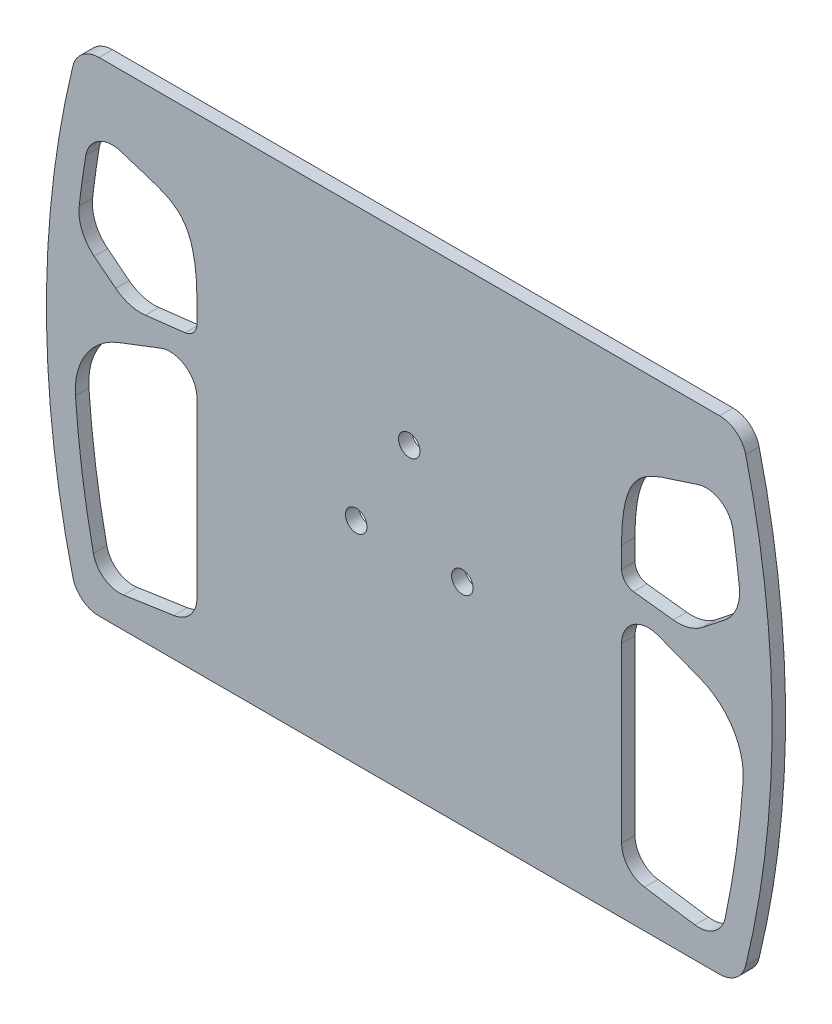
from build123d import *

# Parameters (mm, degrees)
BOSS_EXTRUDE1_DEPTH = 5
SKETCH2_R           = 4
CUT_EXTRUDE1_DEPTH  = 5
CUT_EXTRUDE4_DEPTH  = 35


with BuildPart() as part:
    # Sketch1 → Boss-Extrude1 (new body)
    with BuildSketch(Plane.XY):
        with BuildLine():
            Line((115.454232837, -90), (-115.454232837, -90))
            ThreePointArc((-115.454232837, -90), (-121.637702261, -87.85905248), (-125.173474979, -82.352941176))
            ThreePointArc((-125.173474979, -82.352941176), (-135, 0), (-125.173474979, 82.352941176))
            ThreePointArc((-125.173474979, 82.352941176), (-121.637702261, 87.85905248), (-115.454232837, 90))
            Line((-115.454232837, 90), (115.454232837, 90))
            ThreePointArc((115.454232837, 90), (121.637702261, 87.85905248), (125.173474979, 82.352941176))
            ThreePointArc((125.173474979, 82.352941176), (135, 0), (125.173474979, -82.352941176))
            ThreePointArc((125.173474979, -82.352941176), (121.637702261, -87.85905248), (115.454232837, -90))
        make_face()
    extrude(amount=BOSS_EXTRUDE1_DEPTH)

    # Sketch2 → Cut-Extrude1 (cut)
    with BuildSketch(Plane.XY.offset(5)):
        with Locations((0, 22.8)):
            Circle(SKETCH2_R)
        with Locations((19.745379206, -11.4)):
            Circle(SKETCH2_R)
        with Locations((-19.745379206, -11.4)):
            Circle(SKETCH2_R)
    extrude(amount=-CUT_EXTRUDE1_DEPTH, mode=Mode.SUBTRACT)

    # Sketch4 → Cut-Extrude4 (cut)
    with BuildSketch(Plane.XY.offset(5)):
        with BuildLine():
            Line((92.589613382, 7.756373084), (108.233016215, 1.740021021))
            ThreePointArc((108.233016215, 1.740021021), (120.339926562, -8.155270139), (124.200171868, -23.307582551))
            ThreePointArc((124.200171868, -23.307582551), (121.709079907, -47.191053261), (117.538445446, -70.839129726))
            ThreePointArc((117.538445446, -70.839129726), (113.463443203, -76.968226609), (106.297665816, -78.648436814))
            Line((106.297665816, -78.648436814), (87.539762883, -75.879659935))
            ThreePointArc((87.539762883, -75.879659935), (81.430245342, -72.521282016), (79, -65.986849032))
            Line((79, -65.986849032), (79, -1.577151211))
            ThreePointArc((79, -1.577151211), (83.338557331, 6.665910532), (92.589613382, 7.756373084))
        make_face()
        with BuildLine():
            ThreePointArc((-92.589613382, 7.756373084), (-83.338557331, 6.665910532), (-79, -1.577151211))
            Line((-79, -1.577151211), (-79, -65.986849032))
            ThreePointArc((-79, -65.986849032), (-81.430245342, -72.521282016), (-87.539762883, -75.879659935))
            Line((-87.539762883, -75.879659935), (-106.297665816, -78.648436814))
            ThreePointArc((-106.297665816, -78.648436814), (-113.463443203, -76.968226609), (-117.538445446, -70.839129726))
            ThreePointArc((-117.538445446, -70.839129726), (-121.709079907, -47.191053261), (-124.200171868, -23.307582551))
            ThreePointArc((-124.200171868, -23.307582551), (-120.339926562, -8.155270139), (-108.233016215, 1.740021021))
            Line((-108.233016215, 1.740021021), (-92.589613382, 7.756373084))
        make_face()
        with BuildLine():
            add(Edge.make_bspline(
                [(-107.1656403, 63.712244747), (-105.421734613, 63.094579339), (-103.733740594, 62.553921113), (-100.607161167, 61.582975733), (-99.159247663, 61.147865372), (-96.410321129, 60.288497128), (-95.109448347, 59.864130878), (-92.675824035, 58.977926734), (-91.543513421, 58.51617249), (-89.457956468, 57.516788843), (-88.505180062, 56.979898005), (-86.763629608, 55.791229907), (-85.974064887, 55.140456421), (-84.517341855, 53.654449203), (-83.848519279, 52.818369685), (-82.607884183, 50.851859219), (-82.036322501, 49.719874222), (-81.010476423, 47.056406193), (-80.557249512, 45.52494381), (-79.807126347, 41.990071718), (-79.510581534, 39.987228491), (-79.107044911, 35.456158677), (-79, 32.928236614), (-79, 30.112884289)],
                knots=[0.308064858, 0.308064858, 0.308064858, 0.308064858, 0.375, 0.375, 0.4375, 0.4375, 0.5, 0.5, 0.5625, 0.5625, 0.625, 0.625, 0.6875, 0.6875, 0.75, 0.75, 0.8125, 0.8125, 0.875, 0.875, 0.9375, 0.9375, 1, 1, 1, 1], degree=3))
            Line((-79, 30.112884289), (-79, 22.274807415))
            ThreePointArc((-79, 22.274807415), (-80.264551221, 18.95119155), (-83.418568967, 17.308728685))
            Line((-83.418568967, 17.308728685), (-98.190518564, 15.579221284))
            ThreePointArc((-98.190518564, 15.579221284), (-104.024603132, 16.045769918), (-109.236054023, 18.709412158))
            Line((-109.236054023, 18.709412158), (-117.213085535, 25.01430829))
            ThreePointArc((-117.213085535, 25.01430829), (-121.761034531, 31.020418271), (-122.815466707, 38.480000696))
            ThreePointArc((-122.815466707, 38.480000696), (-121.704826963, 47.22138816), (-120.368031746, 55.931058302))
            ThreePointArc((-120.368031746, 55.931058302), (-115.58177318, 62.901067623), (-107.1656403, 63.712244747))
        make_face()
        with BuildLine():
            add(Edge.make_bspline(
                [(107.1656403, 63.712244747), (105.421734613, 63.094579339), (103.733740594, 62.553921113), (100.607161167, 61.582975733), (99.159247663, 61.147865372), (96.410321129, 60.288497128), (95.109448347, 59.864130878), (92.675824035, 58.977926734), (91.543513421, 58.51617249), (89.457956468, 57.516788843), (88.505180062, 56.979898005), (86.763629608, 55.791229907), (85.974064887, 55.140456421), (84.517341855, 53.654449203), (83.848519279, 52.818369685), (82.607884183, 50.851859219), (82.036322501, 49.719874222), (81.010476423, 47.056406193), (80.557249512, 45.52494381), (79.807126347, 41.990071718), (79.510581534, 39.987228491), (79.107044911, 35.456158677), (79, 32.928236614), (79, 30.112884289)],
                knots=[0.308064858, 0.308064858, 0.308064858, 0.308064858, 0.375, 0.375, 0.4375, 0.4375, 0.5, 0.5, 0.5625, 0.5625, 0.625, 0.625, 0.6875, 0.6875, 0.75, 0.75, 0.8125, 0.8125, 0.875, 0.875, 0.9375, 0.9375, 1, 1, 1, 1], degree=3))
            Line((79, 30.112884289), (79, 22.274807415))
            ThreePointArc((79, 22.274807415), (80.264551221, 18.95119155), (83.418568967, 17.308728685))
            Line((83.418568967, 17.308728685), (98.190518564, 15.579221284))
            ThreePointArc((98.190518564, 15.579221284), (104.024603132, 16.045769918), (109.236054023, 18.709412158))
            Line((109.236054023, 18.709412158), (117.213085535, 25.01430829))
            ThreePointArc((117.213085535, 25.01430829), (121.761034531, 31.020418271), (122.815466707, 38.480000696))
            ThreePointArc((122.815466707, 38.480000696), (121.704826963, 47.22138816), (120.368031746, 55.931058302))
            ThreePointArc((120.368031746, 55.931058302), (115.58177318, 62.901067623), (107.1656403, 63.712244747))
        make_face()
    extrude(amount=-CUT_EXTRUDE4_DEPTH, mode=Mode.SUBTRACT)


solid = part.part
